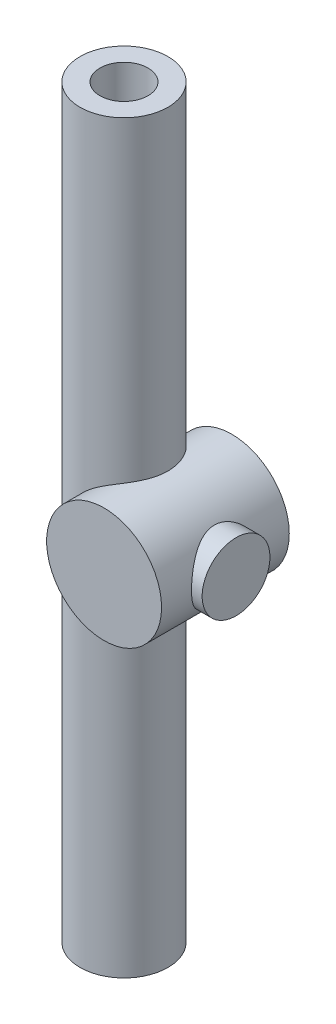
from build123d import *

# Parameters (mm, degrees)
SKETCH1_R           = 27
BOSS_EXTRUDE1_DEPTH = 60
SKETCH2_R           = 20.65
BOSS_EXTRUDE2_DEPTH = 175
SKETCH3_R           = 15.925
BOSS_EXTRUDE3_DEPTH = 32
SKETCH4_R           = 11.295
CUT_EXTRUDE1_DEPTH  = 351.0000001
SKETCH5_R           = 15.925
CUT_EXTRUDE2_DEPTH  = 52


with BuildPart() as part:
    # Sketch1 → Boss-Extrude1 (new body)
    with BuildSketch(Plane.XY):
        Circle(SKETCH1_R)
    extrude(amount=BOSS_EXTRUDE1_DEPTH)

    # Sketch2 → Boss-Extrude2 (add, symmetric)
    with BuildSketch(Plane(origin=(0, 0, 0), x_dir=(1, 0, 0), z_dir=(0, 1, 0))):
        with Locations((-20.65, -30)):
            Circle(SKETCH2_R)
    extrude(amount=BOSS_EXTRUDE2_DEPTH, both=True)

    # Sketch3 → Boss-Extrude3 (add)
    with BuildSketch(Plane(origin=(0, 0, 0), x_dir=(0, 0, -1), z_dir=(1, 0, 0))):
        with Locations((-30, 0)):
            Circle(SKETCH3_R)
    extrude(amount=BOSS_EXTRUDE3_DEPTH)

    # Sketch4 → Cut-Extrude1 (cut, through all)
    with BuildSketch(Plane(origin=(0, 175, 0), x_dir=(1, 0, 0), z_dir=(0, 1, 0))):
        with Locations((-20.65, -30)):
            Circle(SKETCH4_R)
    extrude(amount=-CUT_EXTRUDE1_DEPTH, mode=Mode.SUBTRACT)

    # Sketch5 → Cut-Extrude2 (cut)
    with BuildSketch(Plane(origin=(0, 0, 0), x_dir=(-1, 0, 0), z_dir=(0, 0, -1))):
        Circle(SKETCH5_R)
    extrude(amount=-CUT_EXTRUDE2_DEPTH, mode=Mode.SUBTRACT)


solid = part.part
